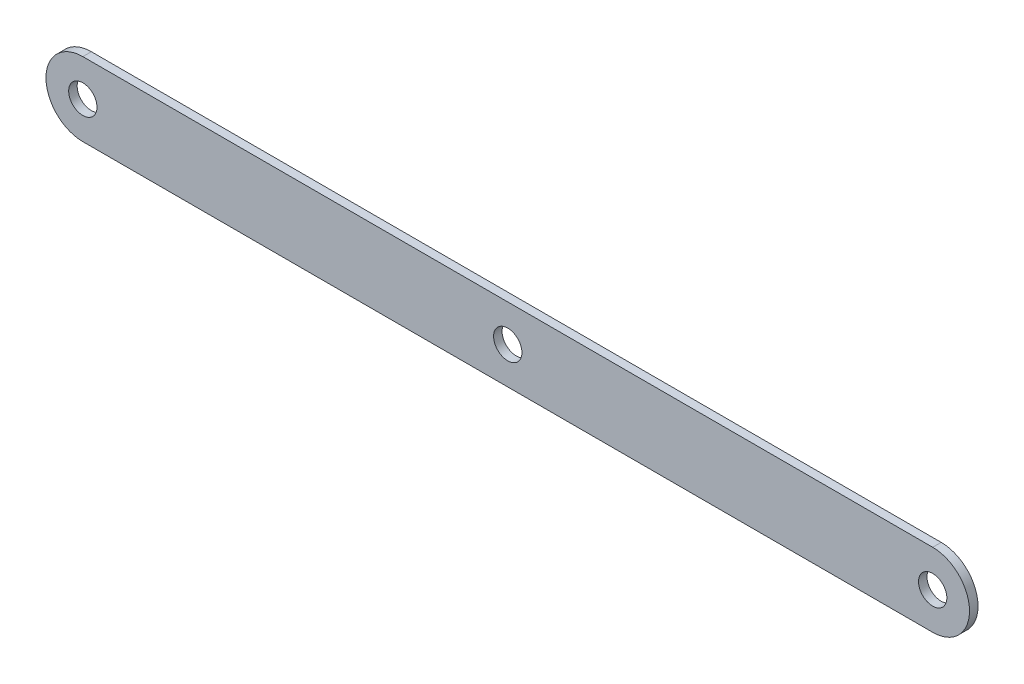
from build123d import *

# Parameters (mm, degrees)
SKETCH1_R           = 2.5
BOSS_EXTRUDE1_DEPTH = 1.5


with BuildPart() as part:
    # Sketch1 → Boss-Extrude1 (new body)
    with BuildSketch(Plane.XY):
        with BuildLine():
            Line((-66.942682106, 0.234876583), (83.057317894, 0.234876583))
            ThreePointArc((83.057317894, 0.234876583), (89.557317894, -6.265123417), (83.057317894, -12.765123417))
            Line((83.057317894, -12.765123417), (-66.942682106, -12.765123417))
            ThreePointArc((-66.942682106, -12.765123417), (-73.442682106, -6.265123417), (-66.942682106, 0.234876583))
        make_face()
        with Locations((-66.942682106, -6.265123417)):
            Circle(SKETCH1_R, mode=Mode.SUBTRACT)
        with Locations((83.057317894, -6.265123417)):
            Circle(SKETCH1_R, mode=Mode.SUBTRACT)
        with Locations((8.057317894, -6.265123417)):
            Circle(SKETCH1_R, mode=Mode.SUBTRACT)
    extrude(amount=BOSS_EXTRUDE1_DEPTH)


solid = part.part
